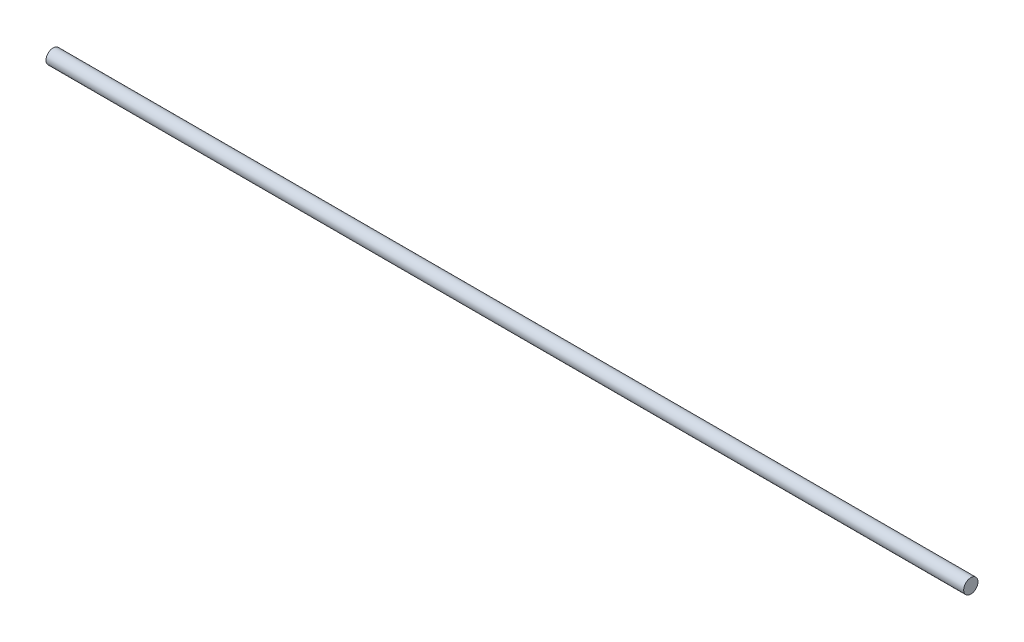
from build123d import *

# Parameters (mm, degrees)
SKETCH1_R           = 3.96875
BOSS_EXTRUDE1_DEPTH = 508


with BuildPart() as part:
    # Sketch1 → Boss-Extrude1 (new body)
    with BuildSketch(Plane(origin=(0, 0, 0), x_dir=(0, 0, -1), z_dir=(1, 0, 0))):
        Circle(SKETCH1_R)
    extrude(amount=BOSS_EXTRUDE1_DEPTH)


solid = part.part
